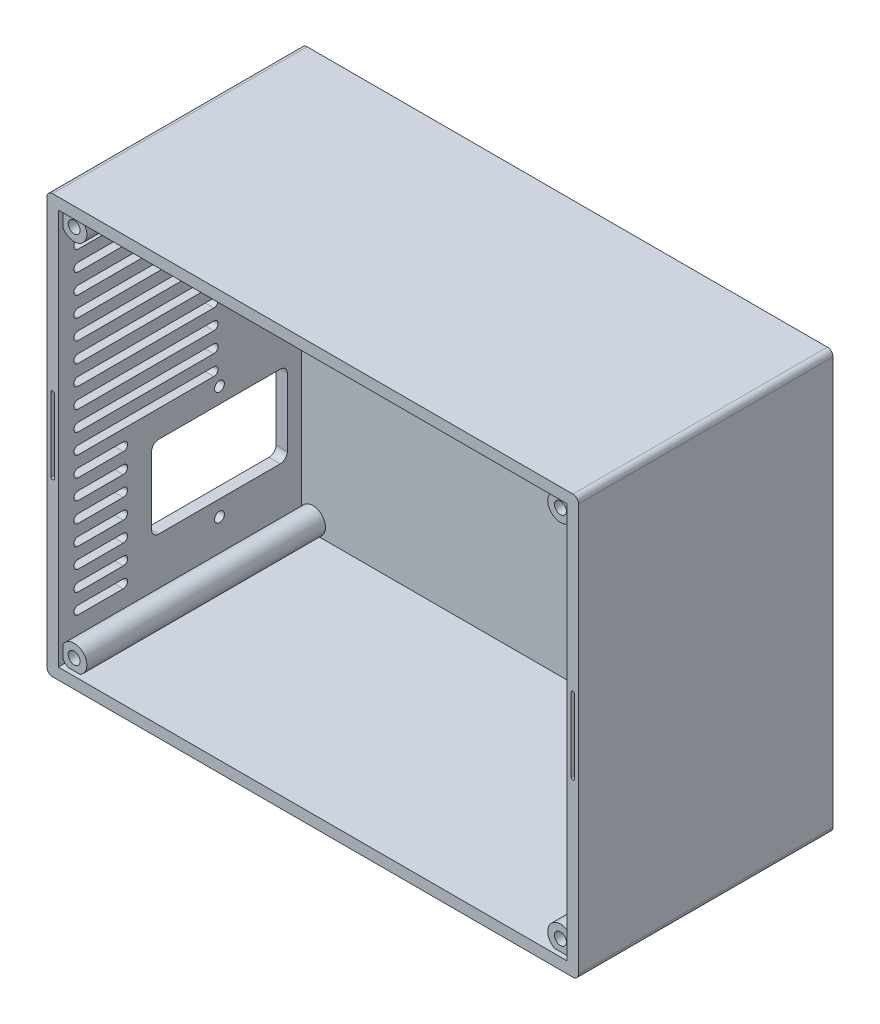
from build123d import *

# Parameters (mm, degrees)
CROQUIS1_W              = 188
CROQUIS1_H              = 148
SALIENTE_EXTRUIR1_DEPTH = 90
CROQUIS6_W              = 180
CROQUIS6_H              = 140
CORTAR_EXTRUIR1_DEPTH   = 87
CROQUIS7_R              = 4.499644431
SALIENTE_EXTRUIR2_DEPTH = 84.4
CORTAR_EXTRUIR3_REACH   = 88
CROQUIS9_R              = 2.1
REDONDEO1_R             = 2
CORTAR_EXTRUIR4_START   = 2
CROQUIS10_R             = 7.5
CORTAR_EXTRUIR4_DEPTH   = 3
CROQUIS15_R             = 1.75
CORTAR_EXTRUIR19_DEPTH  = 4
CORTAR_EXTRUIR23_DEPTH  = 4
MATRIZL1_COUNT          = 2
MATRIZL1_PITCH          = 47.5
CORTAR_EXTRUIR24_DEPTH  = 1.8
CORTAR_EXTRUIR25_REACH  = 190
CROQUIS11_R             = 1.75
CORTAR_EXTRUIR26_REACH  = 190
CORTAR_EXTRUIR27_REACH  = 6
CROQUIS12_R             = 2.1
CROQUIS21_W             = 104
CROQUIS21_H             = 60
CORTAR_EXTRUIR28_DEPTH  = 0.75


with BuildPart() as part:
    # Croquis1 → Saliente-Extruir1 (new body)
    with BuildSketch(Plane.XY):
        with Locations((90, 70)):
            Rectangle(CROQUIS1_W, CROQUIS1_H)
    extrude(amount=SALIENTE_EXTRUIR1_DEPTH)

    # Croquis6 → Cortar-Extruir1 (cut, through all)
    with BuildSketch(Plane(origin=(0, 0, 4), x_dir=(-1, 0, 0), z_dir=(0, 0, -1))):
        with Locations((-90, 70)):
            Rectangle(CROQUIS6_W, CROQUIS6_H)
    extrude(amount=-CORTAR_EXTRUIR1_DEPTH, mode=Mode.SUBTRACT)

    # Croquis7 → Saliente-Extruir2 (add)
    with BuildSketch(Plane(origin=(0, 0, 4), x_dir=(-1, 0, 0), z_dir=(0, 0, -1))):
        with Locations((-4, 136)):
            Circle(CROQUIS7_R)
        with Locations((-176, 136)):
            Circle(CROQUIS7_R)
        with Locations((-176, 4)):
            Circle(CROQUIS7_R)
        with Locations((-4, 4)):
            Circle(CROQUIS7_R)
    extrude(amount=-SALIENTE_EXTRUIR2_DEPTH)

    # Croquis9 → Cortar-Extruir3 (cut, up to next)
    with BuildSketch(Plane(origin=(0, 0, 4), x_dir=(-1, 0, 0), z_dir=(0, 0, -1)), mode=Mode.PRIVATE) as cortar_extruir3_sk1:
        with Locations((-4, 136)):
            Circle(CROQUIS9_R)
    cortar_extruir3_tool1 = extrude(cortar_extruir3_sk1.sketch, amount=-CORTAR_EXTRUIR3_REACH, mode=Mode.PRIVATE) & part.part
    add(cortar_extruir3_tool1.solids().sort_by_distance((4, 136, 4))[0], mode=Mode.SUBTRACT)
    # Croquis9 → Cortar-Extruir3 (cut, up to next)
    with BuildSketch(Plane(origin=(0, 0, 4), x_dir=(-1, 0, 0), z_dir=(0, 0, -1)), mode=Mode.PRIVATE) as cortar_extruir3_sk2:
        with Locations((-176, 136)):
            Circle(CROQUIS9_R)
    cortar_extruir3_tool2 = extrude(cortar_extruir3_sk2.sketch, amount=-CORTAR_EXTRUIR3_REACH, mode=Mode.PRIVATE) & part.part
    add(cortar_extruir3_tool2.solids().sort_by_distance((176, 136, 4))[0], mode=Mode.SUBTRACT)
    # Croquis9 → Cortar-Extruir3 (cut, up to next)
    with BuildSketch(Plane(origin=(0, 0, 4), x_dir=(-1, 0, 0), z_dir=(0, 0, -1)), mode=Mode.PRIVATE) as cortar_extruir3_sk3:
        with Locations((-176, 4)):
            Circle(CROQUIS9_R)
    cortar_extruir3_tool3 = extrude(cortar_extruir3_sk3.sketch, amount=-CORTAR_EXTRUIR3_REACH, mode=Mode.PRIVATE) & part.part
    add(cortar_extruir3_tool3.solids().sort_by_distance((176, 4, 4))[0], mode=Mode.SUBTRACT)
    # Croquis9 → Cortar-Extruir3 (cut, up to next)
    with BuildSketch(Plane(origin=(0, 0, 4), x_dir=(-1, 0, 0), z_dir=(0, 0, -1)), mode=Mode.PRIVATE) as cortar_extruir3_sk4:
        with Locations((-4, 4)):
            Circle(CROQUIS9_R)
    cortar_extruir3_tool4 = extrude(cortar_extruir3_sk4.sketch, amount=-CORTAR_EXTRUIR3_REACH, mode=Mode.PRIVATE) & part.part
    add(cortar_extruir3_tool4.solids().sort_by_distance((4, 4, 4))[0], mode=Mode.SUBTRACT)

    # Redondeo1
    redondeo1_edges = [part.edges().sort_by_distance(p)[0] for p in [
        (-4, 144, 45),
        (184, 144, 45),
        (184, -4, 45),
        (-4, -4, 45),
    ]]
    fillet(redondeo1_edges, radius=REDONDEO1_R)

    # Croquis10 → Cortar-Extruir4 (cut, through all)
    with BuildSketch(Plane(origin=(0, 0, 4), x_dir=(-1, 0, 0), z_dir=(0, 0, -1)).offset(CORTAR_EXTRUIR4_START)):
        with Locations((-16, 124)):
            Circle(CROQUIS10_R)
        with Locations((-164, 124)):
            Circle(CROQUIS10_R)
        with Locations((-164, 16)):
            Circle(CROQUIS10_R)
        with Locations((-16, 16)):
            Circle(CROQUIS10_R)
    extrude(amount=CORTAR_EXTRUIR4_DEPTH, mode=Mode.SUBTRACT)

    # Croquis15 → Cortar-Extruir19 (cut)
    with BuildSketch(Plane(origin=(0, 0, 4), x_dir=(-1, 0, 0), z_dir=(0, 0, -1))):
        with Locations((-160.5, 110.5)):
            Circle(CROQUIS15_R)
        with Locations((-127.5, 110.5)):
            Circle(CROQUIS15_R)
        with Locations((-127.5, 77.5)):
            Circle(CROQUIS15_R)
        with Locations((-160.5, 77.5)):
            Circle(CROQUIS15_R)
    cortar_extruir19 = extrude(amount=CORTAR_EXTRUIR19_DEPTH, mode=Mode.SUBTRACT)

    # Croquis17 → Cortar-Extruir23 (cut)
    with BuildSketch(Plane(origin=(0, 0, 4), x_dir=(-1, 0, 0), z_dir=(0, 0, -1))):
        with BuildLine():
            Line((-143.25, 113.1), (-143.25, 103.1))
            ThreePointArc((-143.25, 103.1), (-144, 102.35), (-144.75, 103.1))
            Line((-144.75, 103.1), (-144.75, 113.1))
            ThreePointArc((-144.75, 113.1), (-144, 113.85), (-143.25, 113.1))
        make_face()
        with BuildLine():
            Line((-140.157277175, 112.724475461), (-142.550433818, 103.015057287))
            ThreePointArc((-142.550433818, 103.015057287), (-142.001714203, 102.107364176), (-141.094021092, 102.65608379))
            Line((-141.094021092, 102.65608379), (-138.700864449, 112.365501965))
            ThreePointArc((-138.700864449, 112.365501965), (-139.249584064, 113.273195076), (-140.157277175, 112.724475461))
        make_face()
        with BuildLine():
            Line((-135.787879433, 111.260752469), (-140.435111154, 102.406192212))
            ThreePointArc((-140.435111154, 102.406192212), (-140.119561513, 101.393557814), (-139.106927115, 101.709107454))
            Line((-139.106927115, 101.709107454), (-134.459695395, 110.563667711))
            ThreePointArc((-134.459695395, 110.563667711), (-134.775245035, 111.576302109), (-135.787879433, 111.260752469))
        make_face()
        with BuildLine():
            Line((-131.895740289, 108.793897284), (-138.526966871, 101.308789802))
            ThreePointArc((-138.526966871, 101.308789802), (-138.462925804, 100.250064747), (-137.404200749, 100.314105815))
            Line((-137.404200749, 100.314105815), (-130.772974166, 107.799213296))
            ThreePointArc((-130.772974166, 107.799213296), (-130.837015234, 108.857938351), (-131.895740289, 108.793897284))
        make_face()
        with BuildLine():
            Line((-128.707056721, 105.467274562), (-136.93689538, 99.786627095))
            ThreePointArc((-136.93689538, 99.786627095), (-137.12808472, 98.743340635), (-136.08479826, 98.552151296))
            Line((-136.08479826, 98.552151296), (-127.854959601, 104.232798763))
            ThreePointArc((-127.854959601, 104.232798763), (-127.663770262, 105.276085223), (-128.707056721, 105.467274562))
        make_face()
        with BuildLine():
            Line((-126.40714343, 101.474215525), (-135.757305857, 97.928166654))
            ThreePointArc((-135.757305857, 97.928166654), (-136.192614374, 96.960950807), (-135.225398526, 96.52564229))
            Line((-135.225398526, 96.52564229), (-125.875236099, 100.071691161))
            ThreePointArc((-125.875236099, 100.071691161), (-125.439927583, 101.038907008), (-126.40714343, 101.474215525))
        make_face()
        with BuildLine():
            Line((-125.129663015, 97.046782248), (-135.056751756, 95.841415446))
            ThreePointArc((-135.056751756, 95.841415446), (-135.710880901, 95.00648128), (-134.875946736, 94.352352135))
            Line((-134.875946736, 94.352352135), (-124.948857995, 95.557718937))
            ThreePointArc((-124.948857995, 95.557718937), (-124.294728849, 96.392653103), (-125.129663015, 97.046782248))
        make_face()
        with BuildLine():
            Line((-124.948857995, 92.442281063), (-134.875946736, 93.647647865))
            ThreePointArc((-134.875946736, 93.647647865), (-135.710880901, 92.99351872), (-135.056751756, 92.158584554))
            Line((-135.056751756, 92.158584554), (-125.129663015, 90.953217752))
            ThreePointArc((-125.129663015, 90.953217752), (-124.294728849, 91.607346897), (-124.948857995, 92.442281063))
        make_face()
        with BuildLine():
            Line((-125.875236099, 87.92830884), (-135.225398526, 91.47435771))
            ThreePointArc((-135.225398526, 91.47435771), (-136.192614374, 91.039049193), (-135.757305857, 90.071833346))
            Line((-135.757305857, 90.071833346), (-126.40714343, 86.525784475))
            ThreePointArc((-126.40714343, 86.525784475), (-125.439927583, 86.961092992), (-125.875236099, 87.92830884))
        make_face()
        with BuildLine():
            Line((-127.854959601, 83.767201237), (-136.08479826, 89.447848704))
            ThreePointArc((-136.08479826, 89.447848704), (-137.12808472, 89.256659365), (-136.93689538, 88.213372905))
            Line((-136.93689538, 88.213372905), (-128.707056721, 82.532725438))
            ThreePointArc((-128.707056721, 82.532725438), (-127.663770262, 82.723914777), (-127.854959601, 83.767201237))
        make_face()
        with BuildLine():
            Line((-130.772974166, 80.200786704), (-137.404200749, 87.685894185))
            ThreePointArc((-137.404200749, 87.685894185), (-138.462925804, 87.749935253), (-138.526966871, 86.691210198))
            Line((-138.526966871, 86.691210198), (-131.895740289, 79.206102716))
            ThreePointArc((-131.895740289, 79.206102716), (-130.837015234, 79.142061649), (-130.772974166, 80.200786704))
        make_face()
        with BuildLine():
            Line((-134.459695395, 77.436332289), (-139.106927115, 86.290892546))
            ThreePointArc((-139.106927115, 86.290892546), (-140.119561513, 86.606442186), (-140.435111154, 85.593807788))
            Line((-140.435111154, 85.593807788), (-135.787879433, 76.739247531))
            ThreePointArc((-135.787879433, 76.739247531), (-134.775245035, 76.423697891), (-134.459695395, 77.436332289))
        make_face()
        with BuildLine():
            Line((-138.700864449, 75.634498035), (-141.094021092, 85.34391621))
            ThreePointArc((-141.094021092, 85.34391621), (-142.001714203, 85.892635824), (-142.550433818, 84.984942713))
            Line((-142.550433818, 84.984942713), (-140.157277175, 75.275524539))
            ThreePointArc((-140.157277175, 75.275524539), (-139.249584064, 74.726804924), (-138.700864449, 75.634498035))
        make_face()
        with BuildLine():
            Line((-143.25, 74.9), (-143.25, 84.9))
            ThreePointArc((-143.25, 84.9), (-144, 85.65), (-144.75, 84.9))
            Line((-144.75, 84.9), (-144.75, 74.9))
            ThreePointArc((-144.75, 74.9), (-144, 74.15), (-143.25, 74.9))
        make_face()
        with BuildLine():
            Line((-147.842722825, 75.275524539), (-145.449566182, 84.984942713))
            ThreePointArc((-145.449566182, 84.984942713), (-145.998285797, 85.892635824), (-146.905978908, 85.34391621))
            Line((-146.905978908, 85.34391621), (-149.299135551, 75.634498035))
            ThreePointArc((-149.299135551, 75.634498035), (-148.750415936, 74.726804924), (-147.842722825, 75.275524539))
        make_face()
        with BuildLine():
            Line((-152.212120567, 76.739247531), (-147.564888846, 85.593807788))
            ThreePointArc((-147.564888846, 85.593807788), (-147.880438487, 86.606442186), (-148.893072885, 86.290892546))
            Line((-148.893072885, 86.290892546), (-153.540304605, 77.436332289))
            ThreePointArc((-153.540304605, 77.436332289), (-153.224754965, 76.423697891), (-152.212120567, 76.739247531))
        make_face()
        with BuildLine():
            Line((-156.104259711, 79.206102716), (-149.473033129, 86.691210198))
            ThreePointArc((-149.473033129, 86.691210198), (-149.537074196, 87.749935253), (-150.595799251, 87.685894185))
            Line((-150.595799251, 87.685894185), (-157.227025834, 80.200786704))
            ThreePointArc((-157.227025834, 80.200786704), (-157.162984766, 79.142061649), (-156.104259711, 79.206102716))
        make_face()
        with BuildLine():
            Line((-159.292943279, 82.532725438), (-151.06310462, 88.213372905))
            ThreePointArc((-151.06310462, 88.213372905), (-150.87191528, 89.256659365), (-151.91520174, 89.447848704))
            Line((-151.91520174, 89.447848704), (-160.145040399, 83.767201237))
            ThreePointArc((-160.145040399, 83.767201237), (-160.336229738, 82.723914777), (-159.292943279, 82.532725438))
        make_face()
        with BuildLine():
            Line((-161.59285657, 86.525784475), (-152.242694143, 90.071833346))
            ThreePointArc((-152.242694143, 90.071833346), (-151.807385626, 91.039049193), (-152.774601474, 91.47435771))
            Line((-152.774601474, 91.47435771), (-162.124763901, 87.928308839))
            ThreePointArc((-162.124763901, 87.928308839), (-162.560072417, 86.961092992), (-161.59285657, 86.525784475))
        make_face()
        with BuildLine():
            Line((-162.870336985, 90.953217752), (-152.943248244, 92.158584554))
            ThreePointArc((-152.943248244, 92.158584554), (-152.289119099, 92.99351872), (-153.124053264, 93.647647865))
            Line((-153.124053264, 93.647647865), (-163.051142005, 92.442281063))
            ThreePointArc((-163.051142005, 92.442281063), (-163.705271151, 91.607346897), (-162.870336985, 90.953217752))
        make_face()
        with BuildLine():
            Line((-163.051142005, 95.557718937), (-153.124053264, 94.352352135))
            ThreePointArc((-153.124053264, 94.352352135), (-152.289119099, 95.00648128), (-152.943248244, 95.841415446))
            Line((-152.943248244, 95.841415446), (-162.870336985, 97.046782248))
            ThreePointArc((-162.870336985, 97.046782248), (-163.705271151, 96.392653103), (-163.051142005, 95.557718937))
        make_face()
        with BuildLine():
            Line((-162.124763901, 100.07169116), (-152.774601474, 96.52564229))
            ThreePointArc((-152.774601474, 96.52564229), (-151.807385626, 96.960950807), (-152.242694143, 97.928166654))
            Line((-152.242694143, 97.928166654), (-161.59285657, 101.474215525))
            ThreePointArc((-161.59285657, 101.474215525), (-162.560072417, 101.038907008), (-162.124763901, 100.07169116))
        make_face()
        with BuildLine():
            Line((-160.145040399, 104.232798763), (-151.91520174, 98.552151296))
            ThreePointArc((-151.91520174, 98.552151296), (-150.87191528, 98.743340635), (-151.06310462, 99.786627095))
            Line((-151.06310462, 99.786627095), (-159.292943279, 105.467274562))
            ThreePointArc((-159.292943279, 105.467274562), (-160.336229738, 105.276085223), (-160.145040399, 104.232798763))
        make_face()
        with BuildLine():
            Line((-157.227025834, 107.799213296), (-150.595799251, 100.314105815))
            ThreePointArc((-150.595799251, 100.314105815), (-149.537074196, 100.250064747), (-149.473033129, 101.308789802))
            Line((-149.473033129, 101.308789802), (-156.104259711, 108.793897284))
            ThreePointArc((-156.104259711, 108.793897284), (-157.162984766, 108.857938351), (-157.227025834, 107.799213296))
        make_face()
        with BuildLine():
            Line((-153.540304605, 110.563667711), (-148.893072885, 101.709107454))
            ThreePointArc((-148.893072885, 101.709107454), (-147.880438487, 101.393557814), (-147.564888846, 102.406192212))
            Line((-147.564888846, 102.406192212), (-152.212120567, 111.260752469))
            ThreePointArc((-152.212120567, 111.260752469), (-153.224754965, 111.576302109), (-153.540304605, 110.563667711))
        make_face()
        with BuildLine():
            Line((-149.299135551, 112.365501965), (-146.905978908, 102.65608379))
            ThreePointArc((-146.905978908, 102.65608379), (-145.998285797, 102.107364176), (-145.449566182, 103.015057287))
            Line((-145.449566182, 103.015057287), (-147.842722825, 112.724475461))
            ThreePointArc((-147.842722825, 112.724475461), (-148.750415936, 113.273195076), (-149.299135551, 112.365501965))
        make_face()
    cortar_extruir23 = extrude(amount=CORTAR_EXTRUIR23_DEPTH, mode=Mode.SUBTRACT)

    # MatrizL1: Cortar-Extruir19, Cortar-Extruir23 ×2
    with Locations(*[(0, -i * MATRIZL1_PITCH, 0) for i in range(1, MATRIZL1_COUNT)]):
        add(cortar_extruir19, mode=Mode.SUBTRACT)
        add(cortar_extruir23, mode=Mode.SUBTRACT)

    # Croquis18 → Cortar-Extruir24 (cut)
    with BuildSketch(Plane.XY.offset(90)):
        with BuildLine():
            Line((-2.6, 57), (-2.6, 83))
            ThreePointArc((-2.6, 83), (-2, 83.6), (-1.4, 83))
            Line((-1.4, 83), (-1.4, 57))
            ThreePointArc((-1.4, 57), (-2, 56.4), (-2.6, 57))
        make_face()
        with BuildLine():
            Line((181.4, 57), (181.4, 83))
            ThreePointArc((181.4, 83), (182, 83.6), (182.6, 83))
            Line((182.6, 83), (182.6, 57))
            ThreePointArc((182.6, 57), (182, 56.4), (181.4, 57))
        make_face()
    extrude(amount=-CORTAR_EXTRUIR24_DEPTH, mode=Mode.SUBTRACT)

    # Croquis11 → Cortar-Extruir25 (cut, up to next)
    with BuildSketch(Plane.ZY.offset(4), mode=Mode.PRIVATE) as cortar_extruir25_sk1:
        with Locations((33, 57.5)):
            Circle(CROQUIS11_R)
    cortar_extruir25_tool1 = extrude(cortar_extruir25_sk1.sketch, amount=-CORTAR_EXTRUIR25_REACH, mode=Mode.PRIVATE) & part.part
    add(cortar_extruir25_tool1.solids().sort_by_distance((-4, 57.5, 33))[0], mode=Mode.SUBTRACT)
    # Croquis11 → Cortar-Extruir25 (cut, up to next)
    with BuildSketch(Plane.ZY.offset(4), mode=Mode.PRIVATE) as cortar_extruir25_sk2:
        with Locations((33, 17.5)):
            Circle(CROQUIS11_R)
    cortar_extruir25_tool2 = extrude(cortar_extruir25_sk2.sketch, amount=-CORTAR_EXTRUIR25_REACH, mode=Mode.PRIVATE) & part.part
    add(cortar_extruir25_tool2.solids().sort_by_distance((-4, 17.5, 33))[0], mode=Mode.SUBTRACT)
    # Croquis11 → Cortar-Extruir25 (cut, up to next)
    with BuildSketch(Plane.ZY.offset(4), mode=Mode.PRIVATE) as cortar_extruir25_sk3:
        with BuildLine():
            Line((11.5, 52), (54.5, 52))
            ThreePointArc((54.5, 52), (56.267766953, 51.267766953), (57, 49.5))
            Line((57, 49.5), (57, 25.5))
            ThreePointArc((57, 25.5), (56.267766953, 23.732233047), (54.5, 23))
            Line((54.5, 23), (11.5, 23))
            ThreePointArc((11.5, 23), (9.732233047, 23.732233047), (9, 25.5))
            Line((9, 25.5), (9, 49.5))
            ThreePointArc((9, 49.5), (9.732233047, 51.267766953), (11.5, 52))
        make_face()
    cortar_extruir25_tool3 = extrude(cortar_extruir25_sk3.sketch, amount=-CORTAR_EXTRUIR25_REACH, mode=Mode.PRIVATE) & part.part
    add(cortar_extruir25_tool3.solids().sort_by_distance((-4, 37.5, 33))[0], mode=Mode.SUBTRACT)

    # Croquis19 → Cortar-Extruir26 (cut, up to next)
    with BuildSketch(Plane.ZY.offset(4), mode=Mode.PRIVATE) as cortar_extruir26_sk1:
        with BuildLine():
            Line((67, 19.5), (83, 19.5))
            ThreePointArc((83, 19.5), (84.5, 21), (83, 22.5))
            Line((83, 22.5), (67, 22.5))
            ThreePointArc((67, 22.5), (65.5, 21), (67, 19.5))
        make_face()
    cortar_extruir26_tool1 = extrude(cortar_extruir26_sk1.sketch, amount=-CORTAR_EXTRUIR26_REACH, mode=Mode.PRIVATE) & part.part
    add(cortar_extruir26_tool1.solids().sort_by_distance((-4, 21, 75))[0], mode=Mode.SUBTRACT)
    # Croquis19 → Cortar-Extruir26 (cut, up to next)
    with BuildSketch(Plane.ZY.offset(4), mode=Mode.PRIVATE) as cortar_extruir26_sk2:
        with BuildLine():
            Line((35, 127.5), (83, 127.5))
            ThreePointArc((83, 127.5), (84.5, 126), (83, 124.5))
            Line((83, 124.5), (35, 124.5))
            ThreePointArc((35, 124.5), (33.5, 126), (35, 127.5))
        make_face()
    cortar_extruir26_tool2 = extrude(cortar_extruir26_sk2.sketch, amount=-CORTAR_EXTRUIR26_REACH, mode=Mode.PRIVATE) & part.part
    add(cortar_extruir26_tool2.solids().sort_by_distance((-4, 126, 59))[0], mode=Mode.SUBTRACT)
    # Croquis19 → Cortar-Extruir26 (cut, up to next)
    with BuildSketch(Plane.ZY.offset(4), mode=Mode.PRIVATE) as cortar_extruir26_sk3:
        with BuildLine():
            Line((35, 120.5), (83, 120.5))
            ThreePointArc((83, 120.5), (84.5, 119), (83, 117.5))
            Line((83, 117.5), (35, 117.5))
            ThreePointArc((35, 117.5), (33.5, 119), (35, 120.5))
        make_face()
    cortar_extruir26_tool3 = extrude(cortar_extruir26_sk3.sketch, amount=-CORTAR_EXTRUIR26_REACH, mode=Mode.PRIVATE) & part.part
    add(cortar_extruir26_tool3.solids().sort_by_distance((-4, 119, 59))[0], mode=Mode.SUBTRACT)
    # Croquis19 → Cortar-Extruir26 (cut, up to next)
    with BuildSketch(Plane.ZY.offset(4), mode=Mode.PRIVATE) as cortar_extruir26_sk4:
        with BuildLine():
            Line((35, 113.5), (83, 113.5))
            ThreePointArc((83, 113.5), (84.5, 112), (83, 110.5))
            Line((83, 110.5), (35, 110.5))
            ThreePointArc((35, 110.5), (33.5, 112), (35, 113.5))
        make_face()
    cortar_extruir26_tool4 = extrude(cortar_extruir26_sk4.sketch, amount=-CORTAR_EXTRUIR26_REACH, mode=Mode.PRIVATE) & part.part
    add(cortar_extruir26_tool4.solids().sort_by_distance((-4, 112, 59))[0], mode=Mode.SUBTRACT)
    # Croquis19 → Cortar-Extruir26 (cut, up to next)
    with BuildSketch(Plane.ZY.offset(4), mode=Mode.PRIVATE) as cortar_extruir26_sk5:
        with BuildLine():
            Line((35, 106.5), (83, 106.5))
            ThreePointArc((83, 106.5), (84.5, 105), (83, 103.5))
            Line((83, 103.5), (35, 103.5))
            ThreePointArc((35, 103.5), (33.5, 105), (35, 106.5))
        make_face()
    cortar_extruir26_tool5 = extrude(cortar_extruir26_sk5.sketch, amount=-CORTAR_EXTRUIR26_REACH, mode=Mode.PRIVATE) & part.part
    add(cortar_extruir26_tool5.solids().sort_by_distance((-4, 105, 59))[0], mode=Mode.SUBTRACT)
    # Croquis19 → Cortar-Extruir26 (cut, up to next)
    with BuildSketch(Plane.ZY.offset(4), mode=Mode.PRIVATE) as cortar_extruir26_sk6:
        with BuildLine():
            Line((67, 26.5), (83, 26.5))
            ThreePointArc((83, 26.5), (84.5, 28), (83, 29.5))
            Line((83, 29.5), (67, 29.5))
            ThreePointArc((67, 29.5), (65.5, 28), (67, 26.5))
        make_face()
    cortar_extruir26_tool6 = extrude(cortar_extruir26_sk6.sketch, amount=-CORTAR_EXTRUIR26_REACH, mode=Mode.PRIVATE) & part.part
    add(cortar_extruir26_tool6.solids().sort_by_distance((-4, 28, 75))[0], mode=Mode.SUBTRACT)
    # Croquis19 → Cortar-Extruir26 (cut, up to next)
    with BuildSketch(Plane.ZY.offset(4), mode=Mode.PRIVATE) as cortar_extruir26_sk7:
        with BuildLine():
            Line((67, 15.5), (83, 15.5))
            ThreePointArc((83, 15.5), (84.5, 14), (83, 12.5))
            Line((83, 12.5), (67, 12.5))
            ThreePointArc((67, 12.5), (65.5, 14), (67, 15.5))
        make_face()
    cortar_extruir26_tool7 = extrude(cortar_extruir26_sk7.sketch, amount=-CORTAR_EXTRUIR26_REACH, mode=Mode.PRIVATE) & part.part
    add(cortar_extruir26_tool7.solids().sort_by_distance((-4, 14, 75))[0], mode=Mode.SUBTRACT)
    # Croquis19 → Cortar-Extruir26 (cut, up to next)
    with BuildSketch(Plane.ZY.offset(4), mode=Mode.PRIVATE) as cortar_extruir26_sk8:
        with BuildLine():
            Line((67, 33.5), (83, 33.5))
            ThreePointArc((83, 33.5), (84.5, 35), (83, 36.5))
            Line((83, 36.5), (67, 36.5))
            ThreePointArc((67, 36.5), (65.5, 35), (67, 33.5))
        make_face()
    cortar_extruir26_tool8 = extrude(cortar_extruir26_sk8.sketch, amount=-CORTAR_EXTRUIR26_REACH, mode=Mode.PRIVATE) & part.part
    add(cortar_extruir26_tool8.solids().sort_by_distance((-4, 35, 75))[0], mode=Mode.SUBTRACT)
    # Croquis19 → Cortar-Extruir26 (cut, up to next)
    with BuildSketch(Plane.ZY.offset(4), mode=Mode.PRIVATE) as cortar_extruir26_sk9:
        with BuildLine():
            Line((67, 40.5), (83, 40.5))
            ThreePointArc((83, 40.5), (84.5, 42), (83, 43.5))
            Line((83, 43.5), (67, 43.5))
            ThreePointArc((67, 43.5), (65.5, 42), (67, 40.5))
        make_face()
    cortar_extruir26_tool9 = extrude(cortar_extruir26_sk9.sketch, amount=-CORTAR_EXTRUIR26_REACH, mode=Mode.PRIVATE) & part.part
    add(cortar_extruir26_tool9.solids().sort_by_distance((-4, 42, 75))[0], mode=Mode.SUBTRACT)
    # Croquis19 → Cortar-Extruir26 (cut, up to next)
    with BuildSketch(Plane.ZY.offset(4), mode=Mode.PRIVATE) as cortar_extruir26_sk10:
        with BuildLine():
            Line((67, 47.5), (83, 47.5))
            ThreePointArc((83, 47.5), (84.5, 49), (83, 50.5))
            Line((83, 50.5), (67, 50.5))
            ThreePointArc((67, 50.5), (65.5, 49), (67, 47.5))
        make_face()
    cortar_extruir26_tool10 = extrude(cortar_extruir26_sk10.sketch, amount=-CORTAR_EXTRUIR26_REACH, mode=Mode.PRIVATE) & part.part
    add(cortar_extruir26_tool10.solids().sort_by_distance((-4, 49, 75))[0], mode=Mode.SUBTRACT)
    # Croquis19 → Cortar-Extruir26 (cut, up to next)
    with BuildSketch(Plane.ZY.offset(4), mode=Mode.PRIVATE) as cortar_extruir26_sk11:
        with BuildLine():
            Line((67, 54.5), (83, 54.5))
            ThreePointArc((83, 54.5), (84.5, 56), (83, 57.5))
            Line((83, 57.5), (67, 57.5))
            ThreePointArc((67, 57.5), (65.5, 56), (67, 54.5))
        make_face()
    cortar_extruir26_tool11 = extrude(cortar_extruir26_sk11.sketch, amount=-CORTAR_EXTRUIR26_REACH, mode=Mode.PRIVATE) & part.part
    add(cortar_extruir26_tool11.solids().sort_by_distance((-4, 56, 75))[0], mode=Mode.SUBTRACT)
    # Croquis19 → Cortar-Extruir26 (cut, up to next)
    with BuildSketch(Plane.ZY.offset(4), mode=Mode.PRIVATE) as cortar_extruir26_sk12:
        with BuildLine():
            Line((35, 99.5), (83, 99.5))
            ThreePointArc((83, 99.5), (84.5, 98), (83, 96.5))
            Line((83, 96.5), (35, 96.5))
            ThreePointArc((35, 96.5), (33.5, 98), (35, 99.5))
        make_face()
    cortar_extruir26_tool12 = extrude(cortar_extruir26_sk12.sketch, amount=-CORTAR_EXTRUIR26_REACH, mode=Mode.PRIVATE) & part.part
    add(cortar_extruir26_tool12.solids().sort_by_distance((-4, 98, 59))[0], mode=Mode.SUBTRACT)
    # Croquis19 → Cortar-Extruir26 (cut, up to next)
    with BuildSketch(Plane.ZY.offset(4), mode=Mode.PRIVATE) as cortar_extruir26_sk13:
        with BuildLine():
            Line((35, 92.5), (83, 92.5))
            ThreePointArc((83, 92.5), (84.5, 91), (83, 89.5))
            Line((83, 89.5), (35, 89.5))
            ThreePointArc((35, 89.5), (33.5, 91), (35, 92.5))
        make_face()
    cortar_extruir26_tool13 = extrude(cortar_extruir26_sk13.sketch, amount=-CORTAR_EXTRUIR26_REACH, mode=Mode.PRIVATE) & part.part
    add(cortar_extruir26_tool13.solids().sort_by_distance((-4, 91, 59))[0], mode=Mode.SUBTRACT)
    # Croquis19 → Cortar-Extruir26 (cut, up to next)
    with BuildSketch(Plane.ZY.offset(4), mode=Mode.PRIVATE) as cortar_extruir26_sk14:
        with BuildLine():
            Line((35, 85.5), (83, 85.5))
            ThreePointArc((83, 85.5), (84.5, 84), (83, 82.5))
            Line((83, 82.5), (35, 82.5))
            ThreePointArc((35, 82.5), (33.5, 84), (35, 85.5))
        make_face()
    cortar_extruir26_tool14 = extrude(cortar_extruir26_sk14.sketch, amount=-CORTAR_EXTRUIR26_REACH, mode=Mode.PRIVATE) & part.part
    add(cortar_extruir26_tool14.solids().sort_by_distance((-4, 84, 59))[0], mode=Mode.SUBTRACT)
    # Croquis19 → Cortar-Extruir26 (cut, up to next)
    with BuildSketch(Plane.ZY.offset(4), mode=Mode.PRIVATE) as cortar_extruir26_sk15:
        with BuildLine():
            Line((35, 78.5), (83, 78.5))
            ThreePointArc((83, 78.5), (84.5, 77), (83, 75.5))
            Line((83, 75.5), (35, 75.5))
            ThreePointArc((35, 75.5), (33.5, 77), (35, 78.5))
        make_face()
    cortar_extruir26_tool15 = extrude(cortar_extruir26_sk15.sketch, amount=-CORTAR_EXTRUIR26_REACH, mode=Mode.PRIVATE) & part.part
    add(cortar_extruir26_tool15.solids().sort_by_distance((-4, 77, 59))[0], mode=Mode.SUBTRACT)
    # Croquis19 → Cortar-Extruir26 (cut, up to next)
    with BuildSketch(Plane.ZY.offset(4), mode=Mode.PRIVATE) as cortar_extruir26_sk16:
        with BuildLine():
            Line((35, 71.5), (83, 71.5))
            ThreePointArc((83, 71.5), (84.5, 70), (83, 68.5))
            Line((83, 68.5), (35, 68.5))
            ThreePointArc((35, 68.5), (33.5, 70), (35, 71.5))
        make_face()
    cortar_extruir26_tool16 = extrude(cortar_extruir26_sk16.sketch, amount=-CORTAR_EXTRUIR26_REACH, mode=Mode.PRIVATE) & part.part
    add(cortar_extruir26_tool16.solids().sort_by_distance((-4, 70, 59))[0], mode=Mode.SUBTRACT)
    # Croquis19 → Cortar-Extruir26 (cut, up to next)
    with BuildSketch(Plane.ZY.offset(4), mode=Mode.PRIVATE) as cortar_extruir26_sk17:
        with BuildLine():
            Line((35, 64.5), (83, 64.5))
            ThreePointArc((83, 64.5), (84.5, 63), (83, 61.5))
            Line((83, 61.5), (35, 61.5))
            ThreePointArc((35, 61.5), (33.5, 63), (35, 64.5))
        make_face()
    cortar_extruir26_tool17 = extrude(cortar_extruir26_sk17.sketch, amount=-CORTAR_EXTRUIR26_REACH, mode=Mode.PRIVATE) & part.part
    add(cortar_extruir26_tool17.solids().sort_by_distance((-4, 63, 59))[0], mode=Mode.SUBTRACT)

    # Croquis12 → Cortar-Extruir27 (cut, up to next)
    with BuildSketch(Plane(origin=(0, 0, 4), x_dir=(-1, 0, 0), z_dir=(0, 0, -1)), mode=Mode.PRIVATE) as cortar_extruir27_sk1:
        with Locations((-93, 125)):
            Circle(CROQUIS12_R)
    cortar_extruir27_tool1 = extrude(cortar_extruir27_sk1.sketch, amount=CORTAR_EXTRUIR27_REACH, mode=Mode.PRIVATE) & part.part
    add(cortar_extruir27_tool1.solids().sort_by_distance((93, 125, 4))[0], mode=Mode.SUBTRACT)
    # Croquis12 → Cortar-Extruir27 (cut, up to next)
    with BuildSketch(Plane(origin=(0, 0, 4), x_dir=(-1, 0, 0), z_dir=(0, 0, -1)), mode=Mode.PRIVATE) as cortar_extruir27_sk2:
        with Locations((-93, 54)):
            Circle(CROQUIS12_R)
    cortar_extruir27_tool2 = extrude(cortar_extruir27_sk2.sketch, amount=CORTAR_EXTRUIR27_REACH, mode=Mode.PRIVATE) & part.part
    add(cortar_extruir27_tool2.solids().sort_by_distance((93, 54, 4))[0], mode=Mode.SUBTRACT)

    # Croquis21 → Cortar-Extruir28 (cut)
    with BuildSketch(Plane(origin=(0, -4, 0), x_dir=(-1, 0, 0), z_dir=(0, -1, 0))):
        with Locations((-90, -45)):
            Rectangle(CROQUIS21_W, CROQUIS21_H)
    extrude(amount=-CORTAR_EXTRUIR28_DEPTH, mode=Mode.SUBTRACT)


solid = part.part
